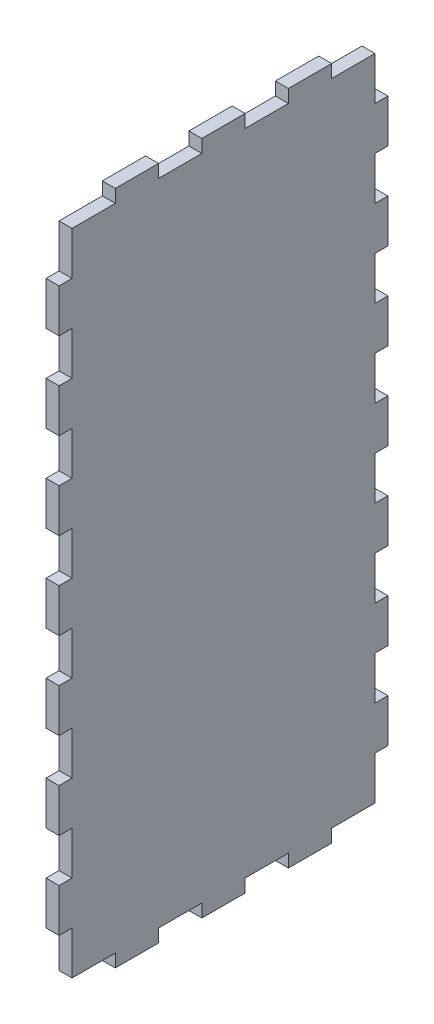
from build123d import *

# Parameters (mm, degrees)
BOSS_EXTRUDE1_DEPTH = 3


with BuildPart() as part:
    # Sketch1 → Boss-Extrude1 (new body)
    with BuildSketch(Plane(origin=(0, 0, 0), x_dir=(0, 0, -1), z_dir=(1, 0, 0))):
        Polygon((10, 153.005875518), (20, 153.005875518), (20, 150.005875518), (30, 150.005875518), (30, 153.005875518), (40, 153.005875518), (40, 150.005875518), (50, 150.005875518), (50, 153.005875518), (60, 153.005875518), (60, 150.005875518), (70, 150.005875518), (70, 140), (73, 140), (73, 130), (70, 130), (70, 120), (73, 120), (73, 110), (70, 110), (70, 100), (73, 100), (73, 90), (70, 90), (70, 80), (73, 80), (73, 70), (70, 70), (70, 60), (73, 60), (73, 50), (70, 50), (70, 40), (73, 40), (73, 30), (70, 30), (70, 20), (73, 20), (73, 10), (70, 10), (70, 0), (60, 0), (60, -3), (50, -3), (50, 0), (40, 0), (40, -3), (30, -3), (30, 0), (20, 0), (20, -3), (10, -3), (10, 0), (0, 0), (0, 10), (-3, 10), (-3, 20), (0, 20), (0, 30), (-3, 30), (-3, 40), (0, 40), (0, 50), (-3, 50), (-3, 60), (0, 60), (0, 70), (-3, 70), (-3, 80), (0, 80), (0, 90), (-3, 90), (-3, 100), (0, 100), (0, 110), (-3, 110), (-3, 120), (0, 120), (0, 130), (-3, 130), (-3, 140), (0, 140), (0, 150.005875518), (10, 150.005875518), align=None)
    extrude(amount=BOSS_EXTRUDE1_DEPTH)


solid = part.part
